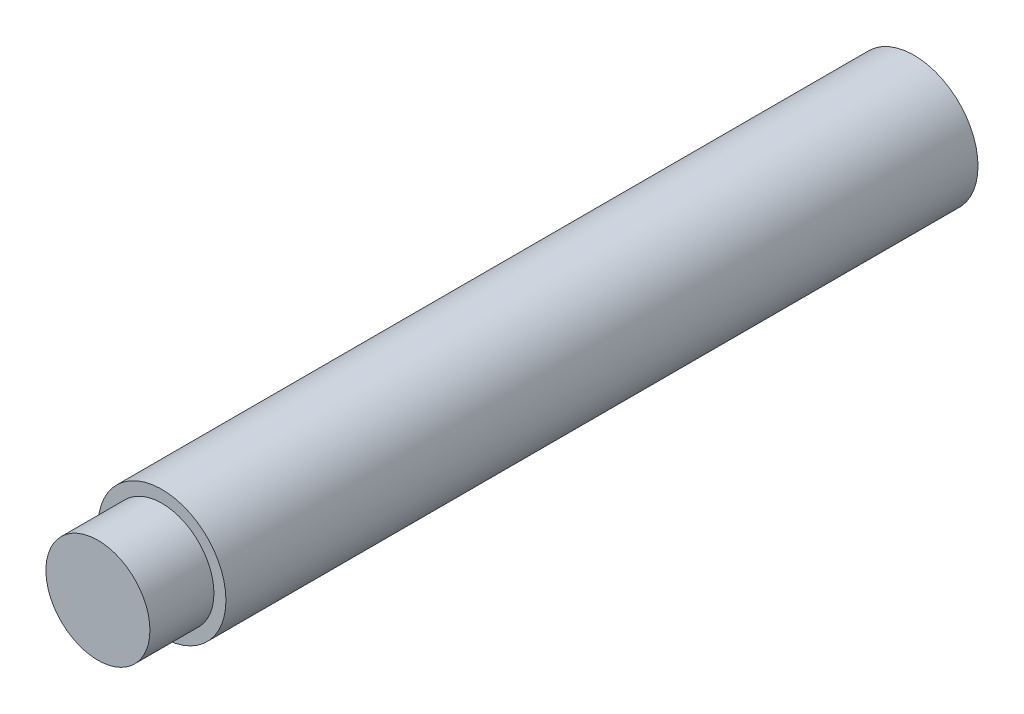
from build123d import *

# Parameters (mm, degrees)
SKETCH_1_R      = 4
EXTRUDE_1_DEPTH = 47
SKETCH_2_R      = 3.25
EXTRUDE_2_DEPTH = 4


with BuildPart() as part:
    # Эскиз1 → Бобышка-Вытянуть1 (new body)
    with BuildSketch(Plane.XY):
        Circle(SKETCH_1_R)
    extrude(amount=EXTRUDE_1_DEPTH)

    # Эскиз2 → Бобышка-Вытянуть2 (add)
    with BuildSketch(Plane.XY.offset(47)):
        Circle(SKETCH_2_R)
    extrude(amount=EXTRUDE_2_DEPTH)


solid = part.part
